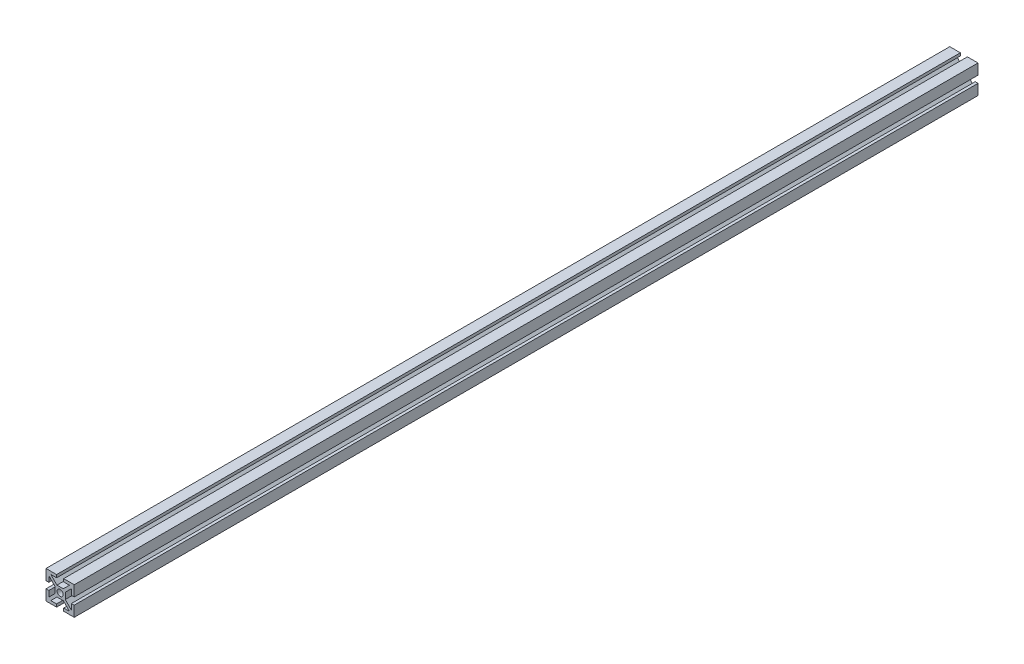
from build123d import *

# Parameters (mm, degrees)
ESQUISSE1_R        = 2.15
BOSS_EXTRU_1_DEPTH = 640


with BuildPart() as part:
    # Esquisse1 → Boss.-Extru.1 (new body)
    with BuildSketch(Plane.XY):
        Polygon((-2.5, 10), (-10, 10), (-10, 2.5), (-8, 2.5), (-8, 6.585786438), (-3.65, 2.235786438), (-3.65, -2.235786438), (-8, -6.585786438), (-8, -2.5), (-10, -2.5), (-10, -10), (-2.5, -10), (-2.5, -8), (-6.585786438, -8), (-2.235786438, -3.65), (2.235786438, -3.65), (6.585786438, -8), (2.5, -8), (2.5, -10), (10, -10), (10, -2.5), (8, -2.5), (8, -6.585786438), (3.65, -2.235786438), (3.65, 2.235786438), (8, 6.585786438), (8, 2.5), (10, 2.5), (10, 10), (2.5, 10), (2.5, 8), (6.585786438, 8), (2.235786438, 3.65), (-2.235786438, 3.65), (-6.585786438, 8), (-2.5, 8), align=None)
        Circle(ESQUISSE1_R, mode=Mode.SUBTRACT)
    extrude(amount=BOSS_EXTRU_1_DEPTH)


solid = part.part
